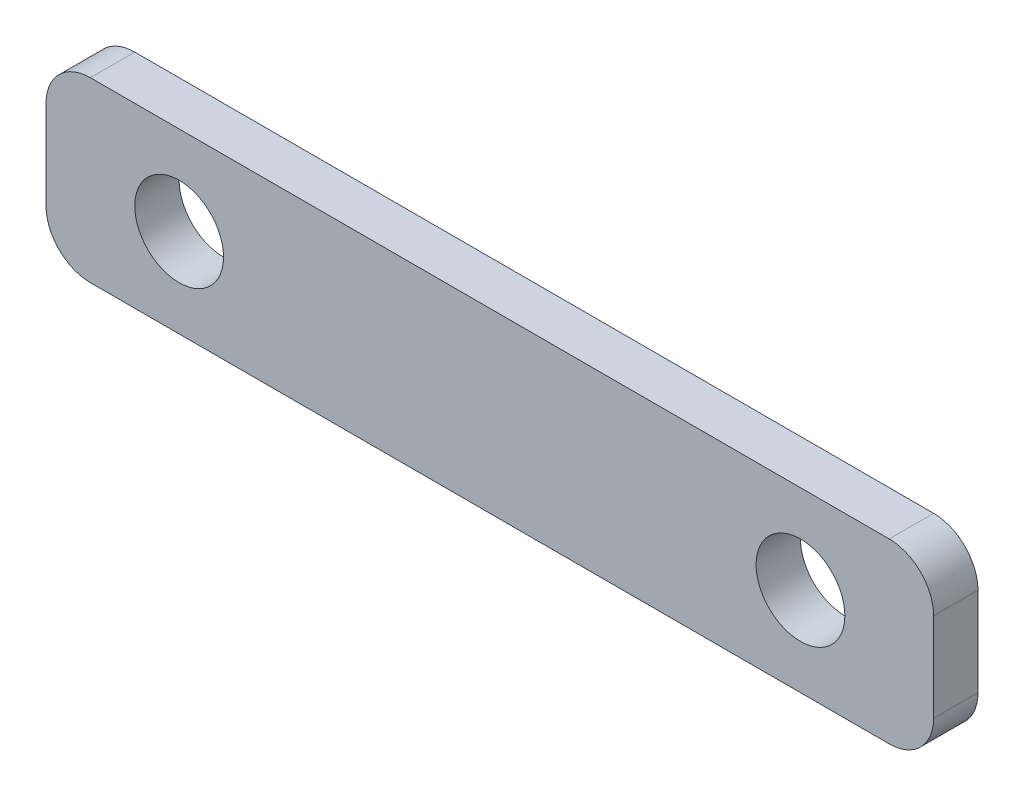
from build123d import *

# Parameters (mm, degrees)
SKETCH1_R           = 10
BOSS_EXTRUDE1_DEPTH = 5


with BuildPart() as part:
    # Sketch1 → Boss-Extrude1 (new body, symmetric)
    with BuildSketch(Plane.XY):
        with BuildLine():
            Line((-190, 150.683938376), (-10, 150.683938376))
            ThreePointArc((-10, 150.683938376), (-2.928932188, 147.755006188), (0, 140.683938376))
            Line((0, 140.683938376), (0, 120.683938376))
            ThreePointArc((0, 120.683938376), (-2.928932188, 113.612870564), (-10, 110.683938376))
            Line((-10, 110.683938376), (-190, 110.683938376))
            ThreePointArc((-190, 110.683938376), (-197.071067812, 113.612870564), (-200, 120.683938376))
            Line((-200, 120.683938376), (-200, 140.683938376))
            ThreePointArc((-200, 140.683938376), (-197.071067812, 147.755006188), (-190, 150.683938376))
        make_face()
        with Locations((-170, 130.683938376)):
            Circle(SKETCH1_R, mode=Mode.SUBTRACT)
        with Locations((-30, 130.683938376)):
            Circle(SKETCH1_R, mode=Mode.SUBTRACT)
    extrude(amount=BOSS_EXTRUDE1_DEPTH, both=True)


solid = part.part
